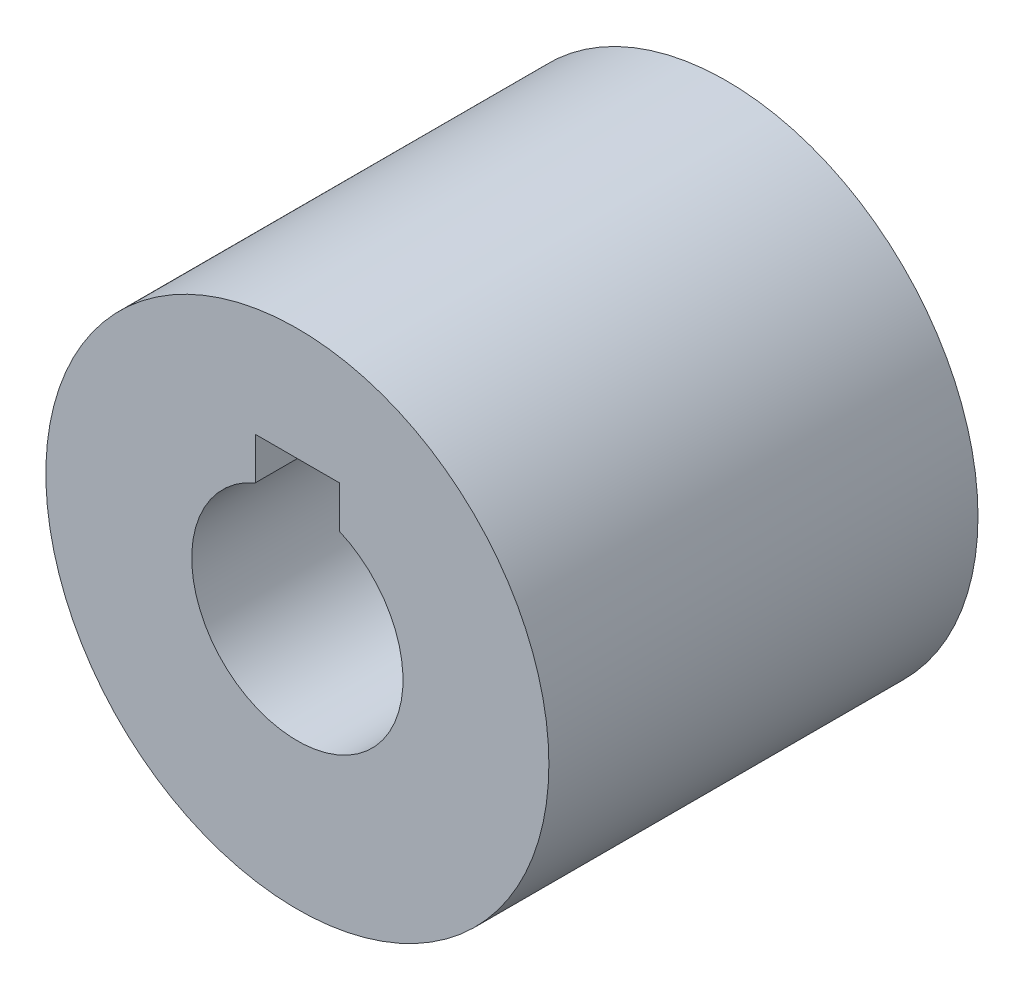
from build123d import *

# Parameters (mm, degrees)
SKETCH1_R           = 9.525
SKETCH1_R_2         = 4
BOSS_EXTRUDE1_DEPTH = 16.25000012
SKETCH2_W           = 3.175
SKETCH2_H           = 1.5875
CUT_EXTRUDE1_DEPTH  = 17.25000012


with BuildPart() as part:
    # Sketch1 → Boss-Extrude1 (new body)
    with BuildSketch(Plane.XY):
        Circle(SKETCH1_R)
        Circle(SKETCH1_R_2, mode=Mode.SUBTRACT)
    extrude(amount=BOSS_EXTRUDE1_DEPTH)

    # Sketch2 → Cut-Extrude1 (cut, through all)
    with BuildSketch(Plane.XY.offset(16.25000012)):
        with Locations((0, 4.465240671)):
            Rectangle(SKETCH2_W, SKETCH2_H)
    extrude(amount=-CUT_EXTRUDE1_DEPTH, mode=Mode.SUBTRACT)


solid = part.part
